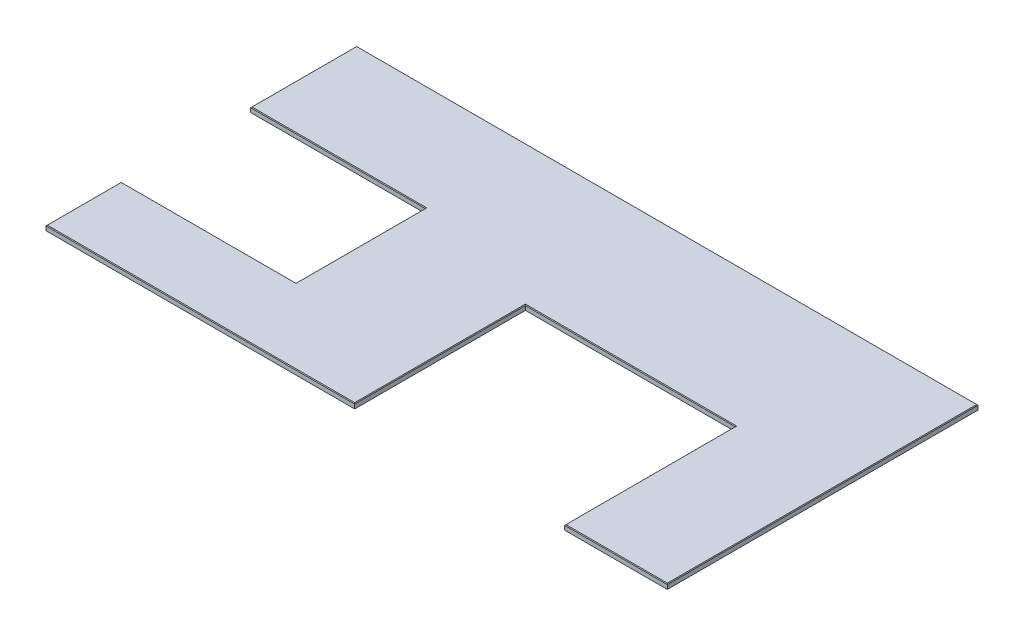
from build123d import *

# Parameters (mm, degrees)
BOSS_EXTRUDE1_DEPTH = 19.05
CHAMFER1_SIZE       = 2.54


with BuildPart() as part:
    # Sketch1 → Boss-Extrude1 (new body)
    with BuildSketch(Plane(origin=(0, 0, 0), x_dir=(1, 0, 0), z_dir=(0, 1, 0))):
        Polygon((1211.5165, 0), (1211.5165, 669.925), (2035.429, 669.925), (2035.429, 0), (2438.4, 0), (2438.4, 1219.2), (0, 1219.2), (0, 803.275), (685.8, 803.275), (685.8, 295.275), (0, 295.275), (0, 0), align=None)
    extrude(amount=-BOSS_EXTRUDE1_DEPTH)

    # Chamfer1
    chamfer1_edges = [part.edges().sort_by_distance(p)[0] for p in [
        (0, 0, -147.6375),
        (342.9, 0, -295.275),
        (685.8, 0, -549.275),
        (342.9, 0, -803.275),
        (0, 0, -1011.2375),
        (1219.2, 0, -1219.2),
        (2438.4, 0, -609.6),
        (2236.9145, 0, 0),
        (2035.429, 0, -334.9625),
        (1623.47275, 0, -669.925),
        (1211.5165, 0, -334.9625),
        (605.75825, 0, 0),
    ]]
    chamfer(chamfer1_edges, length=CHAMFER1_SIZE)


solid = part.part
